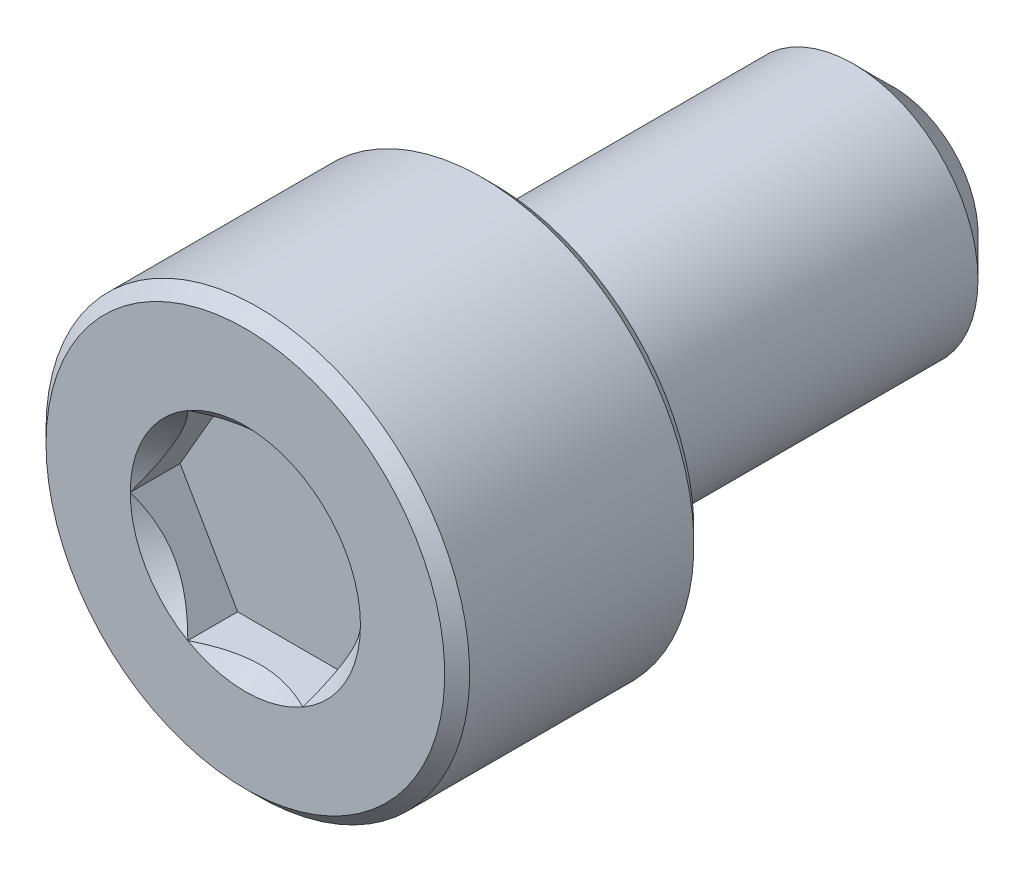
from build123d import *

# Parameters (mm, degrees)
CUT_EXTRUDE1_DEPTH = 1
SKETCH4_R          = 2.309401077
CUT_EXTRUDE2_DEPTH = 0.5
CUT_EXTRUDE2_TAPER = 45


with BuildPart() as part:
    # Sketch2 → Revolve1 (revolve)
    with BuildSketch(Plane(origin=(0, 0, 0), x_dir=(0, 0, -1), z_dir=(1, 0, 0))):
        Polygon((-6.25, 4.25), (-1.75, 4.25), (-1.5, 4), (-1.5, 2.5), (5.7, 2.5), (6.5, 1.7), (6.5, 0), (-6.5, 0), (-6.5, 4), align=None)
    revolve(axis=Axis((0, 0, -6.5), (0, 0, 1)))

    # Sketch3 → Cut-Extrude1 (cut)
    with BuildSketch(Plane.XY.offset(6.5)):
        Polygon((1.154700538, 2), (-1.154700538, 2), (-2.309401077, 0), (-1.154700538, -2), (1.154700538, -2), (2.309401077, 0), align=None)
    extrude(amount=-CUT_EXTRUDE1_DEPTH, mode=Mode.SUBTRACT)

    # Sketch4 → Cut-Extrude2 (cut)
    with BuildSketch(Plane.XY.offset(6.5)):
        Circle(SKETCH4_R)
    extrude(amount=-CUT_EXTRUDE2_DEPTH, taper=CUT_EXTRUDE2_TAPER, mode=Mode.SUBTRACT)


solid = part.part
